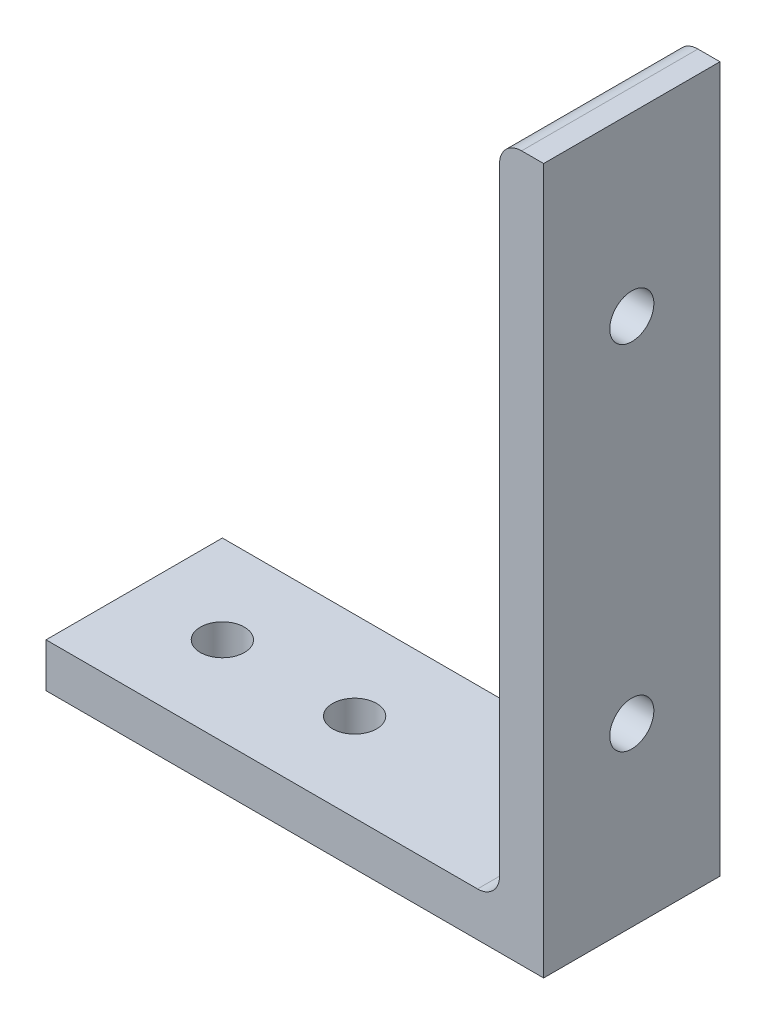
from build123d import *

# Parameters (mm, degrees)
BOSS_EXTRUDE1_DEPTH = 12.7
CUT_EXTRUDE1_REACH  = 78.2
SKETCH3_R           = 3.175
SKETCH4_W           = 28.507373457
SKETCH4_H           = 9.150354521
CUT_EXTRUDE2_DEPTH  = 4.52374
SKETCH5_R           = 3.175
CUT_EXTRUDE3_DEPTH  = 7.35


with BuildPart() as part:
    # Sketch2 → Boss-Extrude1 (new body, symmetric)
    with BuildSketch(Plane.XY):
        with BuildLine():
            Line((-38.1, 0), (38.1, 0))
            Line((38.1, 0), (38.1, 101.6))
            Line((38.1, 101.6), (34.925, 101.6))
            ThreePointArc((34.925, 101.6), (32.67993597, 100.67006403), (31.75, 98.425))
            Line((31.75, 98.425), (31.75, 9.525))
            ThreePointArc((31.75, 9.525), (30.82006403, 7.27993597), (28.575, 6.35))
            Line((28.575, 6.35), (-34.925, 6.35))
            ThreePointArc((-34.925, 6.35), (-37.17006403, 5.42006403), (-38.1, 3.175))
            Line((-38.1, 3.175), (-38.1, 0))
        make_face()
    extrude(amount=BOSS_EXTRUDE1_DEPTH, both=True)

    # Sketch3 → Cut-Extrude1 (cut, up to next)
    with BuildSketch(Plane(origin=(38.1, 0, 0), x_dir=(0, 0, -1), z_dir=(1, 0, 0)), mode=Mode.PRIVATE) as cut_extrude1_sk1:
        with Locations((0, 76.2)):
            Circle(SKETCH3_R)
    cut_extrude1_tool1 = extrude(cut_extrude1_sk1.sketch, amount=-CUT_EXTRUDE1_REACH, mode=Mode.PRIVATE) & part.part
    add(cut_extrude1_tool1.solids().sort_by_distance((38.1, 76.2, 0))[0], mode=Mode.SUBTRACT)
    # Sketch3 → Cut-Extrude1 (cut, up to next)
    with BuildSketch(Plane(origin=(38.1, 0, 0), x_dir=(0, 0, -1), z_dir=(1, 0, 0)), mode=Mode.PRIVATE) as cut_extrude1_sk2:
        with Locations((0, 25.4)):
            Circle(SKETCH3_R)
    cut_extrude1_tool2 = extrude(cut_extrude1_sk2.sketch, amount=-CUT_EXTRUDE1_REACH, mode=Mode.PRIVATE) & part.part
    add(cut_extrude1_tool2.solids().sort_by_distance((38.1, 25.4, 0))[0], mode=Mode.SUBTRACT)

    # Sketch4 → Cut-Extrude2 (cut)
    with BuildSketch(Plane.ZY.offset(38.1)):
        with Locations((1.553686728, 4.575177261)):
            Rectangle(SKETCH4_W, SKETCH4_H)
    extrude(amount=-CUT_EXTRUDE2_DEPTH, mode=Mode.SUBTRACT)

    # Sketch5 → Cut-Extrude3 (cut, through all)
    with BuildSketch(Plane(origin=(0, 6.35, 0), x_dir=(1, 0, 0), z_dir=(0, 1, 0))):
        with Locations((-1.82626, 0)):
            Circle(SKETCH5_R)
        with Locations((-20.87626, 0)):
            Circle(SKETCH5_R)
    extrude(amount=-CUT_EXTRUDE3_DEPTH, mode=Mode.SUBTRACT)


solid = part.part
